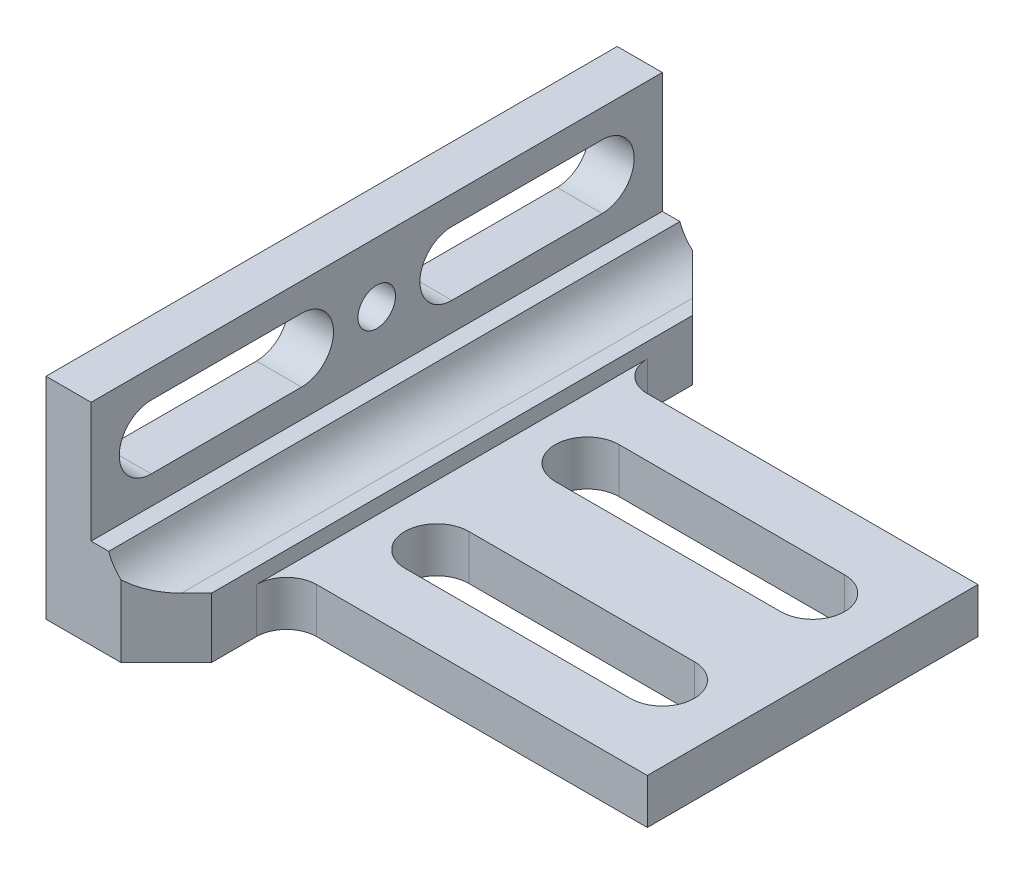
from build123d import *

# Parameters (mm, degrees)
BASESTEELANGLE_DEPTH    = 60.325
CUT_EXTRUDE1_DEPTH      = 1
CUT_EXTRUDE1_DEPTH_BACK = 121.65
CUT_EXTRUDE3_DEPTH      = 13.7
SKETCH5_W               = 76.2
SKETCH5_H               = 6.35
CUT_EXTRUDE4_DEPTH      = 121.65
SKETCH6_W               = 9.525
SKETCH6_H               = 28.575
CUT_EXTRUDE5_DEPTH      = 121.65
CUT_EXTRUDE6_DEPTH      = 10.525
F_3_8_16_TAPPED_HOLE1_D = 7.9375
SKETCH11_W              = 25.4
SKETCH11_H              = 9.525
CUT_EXTRUDE8_DEPTH      = 76.2
FILLET2_R               = 6.35
CHAMFER3_SIZE           = 9.525


with BuildPart() as part:
    # Sketch1 → BaseSteelAngle (new body, symmetric)
    with BuildSketch(Plane.XY):
        with BuildLine():
            Line((0, 0), (0, 101.6))
            Line((0, 101.6), (3.18008, 101.6))
            ThreePointArc((3.18008, 101.6), (9.911679988, 98.811679988), (12.7, 92.08008))
            Line((12.7, 92.08008), (12.7, 22.225))
            ThreePointArc((12.7, 22.225), (15.489807909, 15.489807909), (22.225, 12.7))
            Line((22.225, 12.7), (101.6, 12.7))
            Line((101.6, 12.7), (101.6, 0))
            Line((101.6, 0), (0, 0))
        make_face()
    extrude(amount=BASESTEELANGLE_DEPTH, both=True)

    # Sketch2 → Cut-Extrude1 (cut, two sides)
    with BuildSketch(Plane.XY.offset(60.325)) as cut_extrude1_sk:
        Polygon((-254.455417258, 44.45), (-4.112271749, 44.45), (18.408340367, 44.45), (268.751485876, 44.45), (268.751485876, 545.136291018), (-254.455417258, 545.136291018), align=None)
    extrude(amount=CUT_EXTRUDE1_DEPTH, mode=Mode.SUBTRACT)
    extrude(cut_extrude1_sk.sketch, amount=-CUT_EXTRUDE1_DEPTH_BACK, mode=Mode.SUBTRACT)

    # Sketch4 → Cut-Extrude3 (cut, through all)
    with BuildSketch(Plane(origin=(78.166939161, 12.7, 45.281727152), x_dir=(0, 0, 1), z_dir=(0, 1, 0))):
        with BuildLine():
            Line((-67.902967152, 7.558060839), (-67.902967152, -40.066939161))
            ThreePointArc((-67.902967152, -40.066939161), (-61.156727152, -46.813179161), (-54.410487152, -40.066939161))
            Line((-54.410487152, -40.066939161), (-54.410487152, 7.558060839))
            ThreePointArc((-54.410487152, 7.558060839), (-61.156727152, 14.304300839), (-67.902967152, 7.558060839))
        make_face()
    cut_extrude3 = extrude(amount=-CUT_EXTRUDE3_DEPTH, mode=Mode.SUBTRACT)

    # Mirror1: Cut-Extrude3 across plane
    add(cut_extrude3.mirror(Plane.XY), mode=Mode.SUBTRACT)

    # Sketch5 → Cut-Extrude4 (cut, through all)
    with BuildSketch(Plane(origin=(0, 0, -60.325), x_dir=(-1, 0, 0), z_dir=(0, 0, -1))):
        with Locations((-63.5, 12.7)):
            Rectangle(SKETCH5_W, SKETCH5_H)
    extrude(amount=-CUT_EXTRUDE4_DEPTH, mode=Mode.SUBTRACT)

    # Sketch6 → Cut-Extrude5 (cut, through all)
    with BuildSketch(Plane(origin=(0, 0, -60.325), x_dir=(-1, 0, 0), z_dir=(0, 0, -1))):
        with Locations((-14.2875, 33.3375)):
            Rectangle(SKETCH6_W, SKETCH6_H)
    extrude(amount=-CUT_EXTRUDE5_DEPTH, mode=Mode.SUBTRACT)

    # Sketch7 → Cut-Extrude6 (cut, through all)
    with BuildSketch(Plane(origin=(9.525, 0, 0), x_dir=(0, 0, -1), z_dir=(1, 0, 0))):
        with BuildLine():
            Line((15.875, 25.003125), (47.625, 25.003125))
            ThreePointArc((47.625, 25.003125), (54.371875, 31.75), (47.625, 38.496875))
            Line((47.625, 38.496875), (15.875, 38.496875))
            ThreePointArc((15.875, 38.496875), (9.128125, 31.75), (15.875, 25.003125))
        make_face()
    cut_extrude6 = extrude(amount=-CUT_EXTRUDE6_DEPTH, mode=Mode.SUBTRACT)

    # Mirror2: Cut-Extrude6 across plane
    add(cut_extrude6.mirror(Plane.XY), mode=Mode.SUBTRACT)

    # 3/8-16 Tapped Hole1 (through all)
    with Locations(Plane(origin=(9.525, 0, 0), x_dir=(0, 0, -1), z_dir=(1, 0, 0))):
        with Locations((0, 31.75)):
            Hole(F_3_8_16_TAPPED_HOLE1_D / 2)

    # Sketch11 → Cut-Extrude8 (cut)
    with BuildSketch(Plane(origin=(101.6, 0, 0), x_dir=(0, 0, -1), z_dir=(1, 0, 0))):
        with Locations((47.625, 4.7625)):
            Rectangle(SKETCH11_W, SKETCH11_H)
        with Locations((-47.625, 4.7625)):
            Rectangle(SKETCH11_W, SKETCH11_H)
    extrude(amount=-CUT_EXTRUDE8_DEPTH, mode=Mode.SUBTRACT)

    # Fillet2
    fillet2_edges = [part.edges().sort_by_distance(p)[0] for p in [
        (25.4, 4.7625, -34.925),
        (25.4, 4.7625, 34.925),
    ]]
    fillet(fillet2_edges, radius=FILLET2_R)

    # Chamfer3
    chamfer3_edges = [part.edges().sort_by_distance(p)[0] for p in [
        (25.4, 6.35, 60.325),
        (25.4, 6.35, -60.325),
    ]]
    chamfer(chamfer3_edges, length=CHAMFER3_SIZE)


solid = part.part
